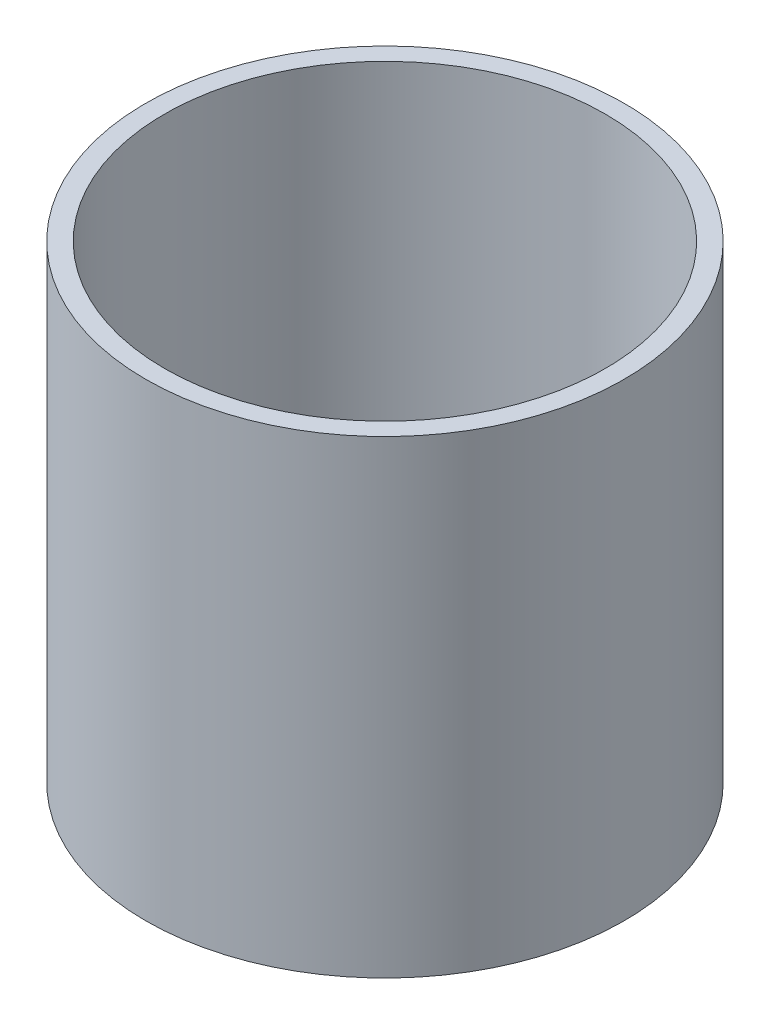
from build123d import *

# Parameters (mm, degrees)
SKETCH1_R           = 25.5
SKETCH1_R_2         = 23.5
BOSS_EXTRUDE1_DEPTH = 50


with BuildPart() as part:
    # Sketch1 → Boss-Extrude1 (new body)
    with BuildSketch(Plane(origin=(0, 0, 0), x_dir=(1, 0, 0), z_dir=(0, 1, 0))):
        Circle(SKETCH1_R)
        Circle(SKETCH1_R_2, mode=Mode.SUBTRACT)
    extrude(amount=BOSS_EXTRUDE1_DEPTH)


solid = part.part
